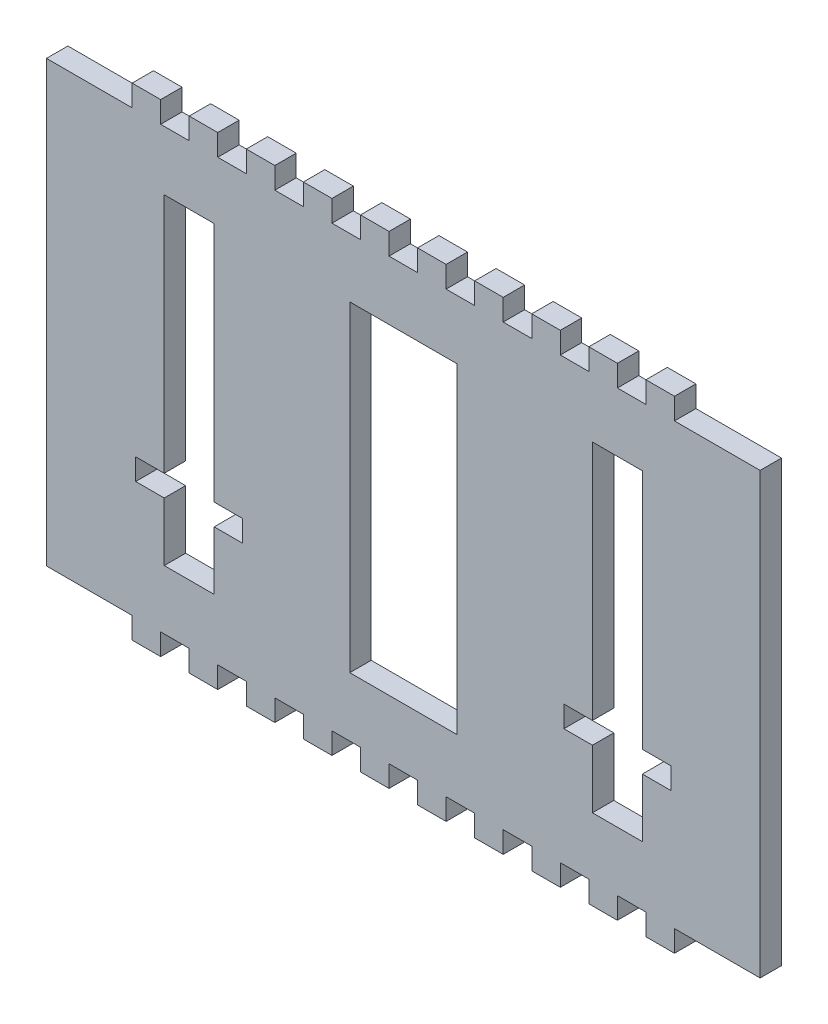
from build123d import *

# Parameters (mm, degrees)
SKETCH1_W                = 100
SKETCH1_H                = 67.6
BOSS_EXTRUDE1_DEPTH      = 3
SKETCH3_W                = 4
SKETCH3_H                = 3
CUT_EXTRUDE1_DEPTH       = 10
LPATTERN1_COUNT          = 13
LPATTERN1_PITCH          = 8
SKETCH7_W                = 15
SKETCH7_H                = 45
CUT_EXTRUDE5_DEPTH       = 3
MIRROR1_COPY_1_SKETCH_W  = 4
MIRROR1_COPY_1_SKETCH_H  = 3
MIRROR1_COPY_1_DEPTH     = 10
MIRROR1_COPY_2_SKETCH_W  = 4
MIRROR1_COPY_2_SKETCH_H  = 3
MIRROR1_COPY_2_DEPTH     = 10
MIRROR1_COPY_3_SKETCH_W  = 4
MIRROR1_COPY_3_SKETCH_H  = 3
MIRROR1_COPY_3_DEPTH     = 10
MIRROR1_COPY_4_SKETCH_W  = 4
MIRROR1_COPY_4_SKETCH_H  = 3
MIRROR1_COPY_4_DEPTH     = 10
MIRROR1_COPY_5_SKETCH_W  = 4
MIRROR1_COPY_5_SKETCH_H  = 3
MIRROR1_COPY_5_DEPTH     = 10
MIRROR1_COPY_6_SKETCH_W  = 4
MIRROR1_COPY_6_SKETCH_H  = 3
MIRROR1_COPY_6_DEPTH     = 10
MIRROR1_COPY_7_SKETCH_W  = 4
MIRROR1_COPY_7_SKETCH_H  = 3
MIRROR1_COPY_7_DEPTH     = 10
MIRROR1_COPY_8_SKETCH_W  = 4
MIRROR1_COPY_8_SKETCH_H  = 3
MIRROR1_COPY_8_DEPTH     = 10
MIRROR1_COPY_9_SKETCH_W  = 4
MIRROR1_COPY_9_SKETCH_H  = 3
MIRROR1_COPY_9_DEPTH     = 10
MIRROR1_COPY_10_SKETCH_W = 4
MIRROR1_COPY_10_SKETCH_H = 3
MIRROR1_COPY_10_DEPTH    = 10
MIRROR1_COPY_11_SKETCH_W = 4
MIRROR1_COPY_11_SKETCH_H = 3
MIRROR1_COPY_11_DEPTH    = 10
MIRROR1_COPY_12_SKETCH_W = 4
MIRROR1_COPY_12_SKETCH_H = 3
MIRROR1_COPY_12_DEPTH    = 10
LPATTERN2_COUNT          = 2
LPATTERN2_PITCH          = 30
LPATTERN2_COL_COUNT      = 2
LPATTERN2_COL_PITCH      = 30
SKETCH8_W                = 4
SKETCH8_H                = 8.2
SKETCH8_H_2              = 33.8
BOSS_EXTRUDE2_DEPTH      = 3
CUT_EXTRUDE6_REACH       = 5
SKETCH9_W                = 12
SKETCH9_H                = 3


with BuildPart() as part:
    # Sketch1 → Boss-Extrude1 (new body)
    with BuildSketch(Plane.XY):
        Rectangle(SKETCH1_W, SKETCH1_H)
    extrude(amount=BOSS_EXTRUDE1_DEPTH)

    # Sketch3 → Cut-Extrude1 (cut)
    with BuildSketch(Plane(origin=(0, 0, 0), x_dir=(-1, 0, 0), z_dir=(0, 0, -1))):
        with Locations((-48, -32.3)):
            Rectangle(SKETCH3_W, SKETCH3_H)
    cut_extrude1 = extrude(amount=-CUT_EXTRUDE1_DEPTH, mode=Mode.SUBTRACT)

    # LPattern1: Cut-Extrude1 ×13
    with Locations(*[(-i * LPATTERN1_PITCH, 0, 0) for i in range(1, LPATTERN1_COUNT)]):
        add(cut_extrude1, mode=Mode.SUBTRACT)

    # Sketch7 → Cut-Extrude5 (cut)
    with BuildSketch(Plane(origin=(0, 0, 0), x_dir=(-1, 0, 0), z_dir=(0, 0, -1))):
        Rectangle(SKETCH7_W, SKETCH7_H)
    cut_extrude5 = extrude(amount=-CUT_EXTRUDE5_DEPTH, mode=Mode.SUBTRACT)

    # Mirror1: Cut-Extrude1 across plane
    add(cut_extrude1.mirror(Plane.ZX), mode=Mode.SUBTRACT)

    # Mirror1 copy 1 sketch → Mirror1 copy 1 (cut)
    with BuildSketch(Plane(origin=(-8, 0, 0), x_dir=(-1, 0, 0), z_dir=(0, 0, -1))):
        with Locations((-48, 32.3)):
            Rectangle(MIRROR1_COPY_1_SKETCH_W, MIRROR1_COPY_1_SKETCH_H)
    extrude(amount=-MIRROR1_COPY_1_DEPTH, mode=Mode.SUBTRACT)

    # Mirror1 copy 2 sketch → Mirror1 copy 2 (cut)
    with BuildSketch(Plane(origin=(-16, 0, 0), x_dir=(-1, 0, 0), z_dir=(0, 0, -1))):
        with Locations((-48, 32.3)):
            Rectangle(MIRROR1_COPY_2_SKETCH_W, MIRROR1_COPY_2_SKETCH_H)
    extrude(amount=-MIRROR1_COPY_2_DEPTH, mode=Mode.SUBTRACT)

    # Mirror1 copy 3 sketch → Mirror1 copy 3 (cut)
    with BuildSketch(Plane(origin=(-24, 0, 0), x_dir=(-1, 0, 0), z_dir=(0, 0, -1))):
        with Locations((-48, 32.3)):
            Rectangle(MIRROR1_COPY_3_SKETCH_W, MIRROR1_COPY_3_SKETCH_H)
    extrude(amount=-MIRROR1_COPY_3_DEPTH, mode=Mode.SUBTRACT)

    # Mirror1 copy 4 sketch → Mirror1 copy 4 (cut)
    with BuildSketch(Plane(origin=(-32, 0, 0), x_dir=(-1, 0, 0), z_dir=(0, 0, -1))):
        with Locations((-48, 32.3)):
            Rectangle(MIRROR1_COPY_4_SKETCH_W, MIRROR1_COPY_4_SKETCH_H)
    extrude(amount=-MIRROR1_COPY_4_DEPTH, mode=Mode.SUBTRACT)

    # Mirror1 copy 5 sketch → Mirror1 copy 5 (cut)
    with BuildSketch(Plane(origin=(-40, 0, 0), x_dir=(-1, 0, 0), z_dir=(0, 0, -1))):
        with Locations((-48, 32.3)):
            Rectangle(MIRROR1_COPY_5_SKETCH_W, MIRROR1_COPY_5_SKETCH_H)
    extrude(amount=-MIRROR1_COPY_5_DEPTH, mode=Mode.SUBTRACT)

    # Mirror1 copy 6 sketch → Mirror1 copy 6 (cut)
    with BuildSketch(Plane(origin=(-48, 0, 0), x_dir=(-1, 0, 0), z_dir=(0, 0, -1))):
        with Locations((-48, 32.3)):
            Rectangle(MIRROR1_COPY_6_SKETCH_W, MIRROR1_COPY_6_SKETCH_H)
    extrude(amount=-MIRROR1_COPY_6_DEPTH, mode=Mode.SUBTRACT)

    # Mirror1 copy 7 sketch → Mirror1 copy 7 (cut)
    with BuildSketch(Plane(origin=(-56, 0, 0), x_dir=(-1, 0, 0), z_dir=(0, 0, -1))):
        with Locations((-48, 32.3)):
            Rectangle(MIRROR1_COPY_7_SKETCH_W, MIRROR1_COPY_7_SKETCH_H)
    extrude(amount=-MIRROR1_COPY_7_DEPTH, mode=Mode.SUBTRACT)

    # Mirror1 copy 8 sketch → Mirror1 copy 8 (cut)
    with BuildSketch(Plane(origin=(-64, 0, 0), x_dir=(-1, 0, 0), z_dir=(0, 0, -1))):
        with Locations((-48, 32.3)):
            Rectangle(MIRROR1_COPY_8_SKETCH_W, MIRROR1_COPY_8_SKETCH_H)
    extrude(amount=-MIRROR1_COPY_8_DEPTH, mode=Mode.SUBTRACT)

    # Mirror1 copy 9 sketch → Mirror1 copy 9 (cut)
    with BuildSketch(Plane(origin=(-72, 0, 0), x_dir=(-1, 0, 0), z_dir=(0, 0, -1))):
        with Locations((-48, 32.3)):
            Rectangle(MIRROR1_COPY_9_SKETCH_W, MIRROR1_COPY_9_SKETCH_H)
    extrude(amount=-MIRROR1_COPY_9_DEPTH, mode=Mode.SUBTRACT)

    # Mirror1 copy 10 sketch → Mirror1 copy 10 (cut)
    with BuildSketch(Plane(origin=(-80, 0, 0), x_dir=(-1, 0, 0), z_dir=(0, 0, -1))):
        with Locations((-48, 32.3)):
            Rectangle(MIRROR1_COPY_10_SKETCH_W, MIRROR1_COPY_10_SKETCH_H)
    extrude(amount=-MIRROR1_COPY_10_DEPTH, mode=Mode.SUBTRACT)

    # Mirror1 copy 11 sketch → Mirror1 copy 11 (cut)
    with BuildSketch(Plane(origin=(-88, 0, 0), x_dir=(-1, 0, 0), z_dir=(0, 0, -1))):
        with Locations((-48, 32.3)):
            Rectangle(MIRROR1_COPY_11_SKETCH_W, MIRROR1_COPY_11_SKETCH_H)
    extrude(amount=-MIRROR1_COPY_11_DEPTH, mode=Mode.SUBTRACT)

    # Mirror1 copy 12 sketch → Mirror1 copy 12 (cut)
    with BuildSketch(Plane(origin=(-96, 0, 0), x_dir=(-1, 0, 0), z_dir=(0, 0, -1))):
        with Locations((-48, 32.3)):
            Rectangle(MIRROR1_COPY_12_SKETCH_W, MIRROR1_COPY_12_SKETCH_H)
    extrude(amount=-MIRROR1_COPY_12_DEPTH, mode=Mode.SUBTRACT)

    # LPattern2: Cut-Extrude5 ×2
    with Locations(*[(-i * LPATTERN2_PITCH, 0, 0) for i in range(1, LPATTERN2_COUNT)]):
        add(cut_extrude5, mode=Mode.SUBTRACT)

    # LPattern2 col: Cut-Extrude5 ×2
    with Locations(*[(i * LPATTERN2_COL_PITCH, 0, 0) for i in range(1, LPATTERN2_COL_COUNT)]):
        add(cut_extrude5, mode=Mode.SUBTRACT)

    # Sketch8 → Boss-Extrude2 (add)
    with BuildSketch(Plane.XY.offset(3)):
        with Locations((24.5, -18.4)):
            Rectangle(SKETCH8_W, SKETCH8_H)
        with Locations((24.5, 5.6)):
            Rectangle(SKETCH8_W, SKETCH8_H_2)
        with Locations((35.5, 5.6)):
            Rectangle(SKETCH8_W, SKETCH8_H_2)
        with Locations((35.5, -18.4)):
            Rectangle(SKETCH8_W, SKETCH8_H)
    boss_extrude2 = extrude(amount=-BOSS_EXTRUDE2_DEPTH)

    # Mirror2: Boss-Extrude2 across plane
    add(boss_extrude2.mirror(Plane(origin=(0, 0, 0), x_dir=(0, 0, 1), z_dir=(1, 0, 0))))

    # Sketch9 → Cut-Extrude6 (cut, up to next)
    with BuildSketch(Plane(origin=(0, 0, 0), x_dir=(-1, 0, 0), z_dir=(0, 0, -1)), mode=Mode.PRIVATE) as cut_extrude6_sk1:
        with Locations((-44, 32.3)):
            Rectangle(SKETCH9_W, SKETCH9_H)
    cut_extrude6_tool1 = extrude(cut_extrude6_sk1.sketch, amount=-CUT_EXTRUDE6_REACH, mode=Mode.PRIVATE) & part.part
    add(cut_extrude6_tool1.solids().sort_by_distance((44, 32.3, 0))[0], mode=Mode.SUBTRACT)
    # Sketch9 → Cut-Extrude6 (cut, up to next)
    with BuildSketch(Plane(origin=(0, 0, 0), x_dir=(-1, 0, 0), z_dir=(0, 0, -1)), mode=Mode.PRIVATE) as cut_extrude6_sk2:
        with Locations((44, 32.3)):
            Rectangle(SKETCH9_W, SKETCH9_H)
    cut_extrude6_tool2 = extrude(cut_extrude6_sk2.sketch, amount=-CUT_EXTRUDE6_REACH, mode=Mode.PRIVATE) & part.part
    add(cut_extrude6_tool2.solids().sort_by_distance((-44, 32.3, 0))[0], mode=Mode.SUBTRACT)
    # Sketch9 → Cut-Extrude6 (cut, up to next)
    with BuildSketch(Plane(origin=(0, 0, 0), x_dir=(-1, 0, 0), z_dir=(0, 0, -1)), mode=Mode.PRIVATE) as cut_extrude6_sk3:
        with Locations((44, -32.3)):
            Rectangle(SKETCH9_W, SKETCH9_H)
    cut_extrude6_tool3 = extrude(cut_extrude6_sk3.sketch, amount=-CUT_EXTRUDE6_REACH, mode=Mode.PRIVATE) & part.part
    add(cut_extrude6_tool3.solids().sort_by_distance((-44, -32.3, 0))[0], mode=Mode.SUBTRACT)
    # Sketch9 → Cut-Extrude6 (cut, up to next)
    with BuildSketch(Plane(origin=(0, 0, 0), x_dir=(-1, 0, 0), z_dir=(0, 0, -1)), mode=Mode.PRIVATE) as cut_extrude6_sk4:
        with Locations((-44, -32.3)):
            Rectangle(SKETCH9_W, SKETCH9_H)
    cut_extrude6_tool4 = extrude(cut_extrude6_sk4.sketch, amount=-CUT_EXTRUDE6_REACH, mode=Mode.PRIVATE) & part.part
    add(cut_extrude6_tool4.solids().sort_by_distance((44, -32.3, 0))[0], mode=Mode.SUBTRACT)


solid = part.part
